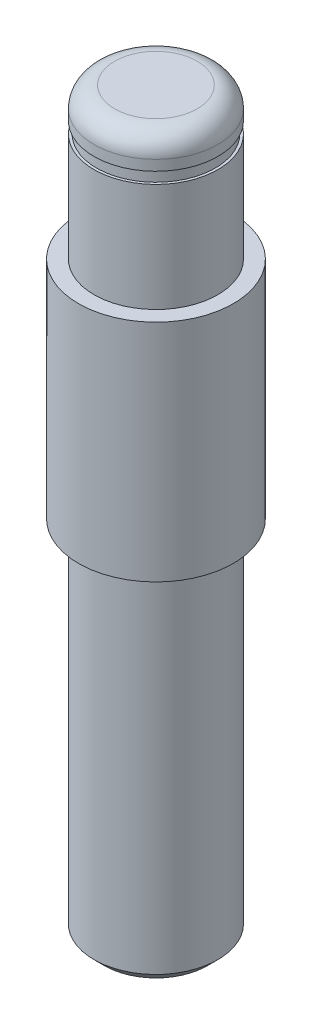
from build123d import *


with BuildPart() as part:
    # Sketch1 → Revolve1 (revolve)
    with BuildSketch(Plane.XY):
        with BuildLine():
            Line((0, 71.4), (0, 0))
            Line((0, 0), (5, 0))
            Line((5, 0), (6, 1))
            Line((6, 1), (6, 35))
            Line((6, 35), (7.5, 35))
            Line((7.5, 35), (7.5, 56.8))
            Line((7.5, 56.8), (6, 56.8))
            Line((6, 56.8), (6, 67.3))
            Line((6, 67.3), (5.75, 67.3))
            Line((5.75, 67.3), (5.75, 68.4))
            Line((5.75, 68.4), (6, 68.4))
            Line((6, 68.4), (6, 69.4))
            ThreePointArc((6, 69.4), (5.414213562, 70.814213562), (4, 71.4))
            Line((4, 71.4), (0, 71.4))
        make_face()
    revolve(axis=Axis((0, 71.4, 0), (0, -1, 0)))


solid = part.part
